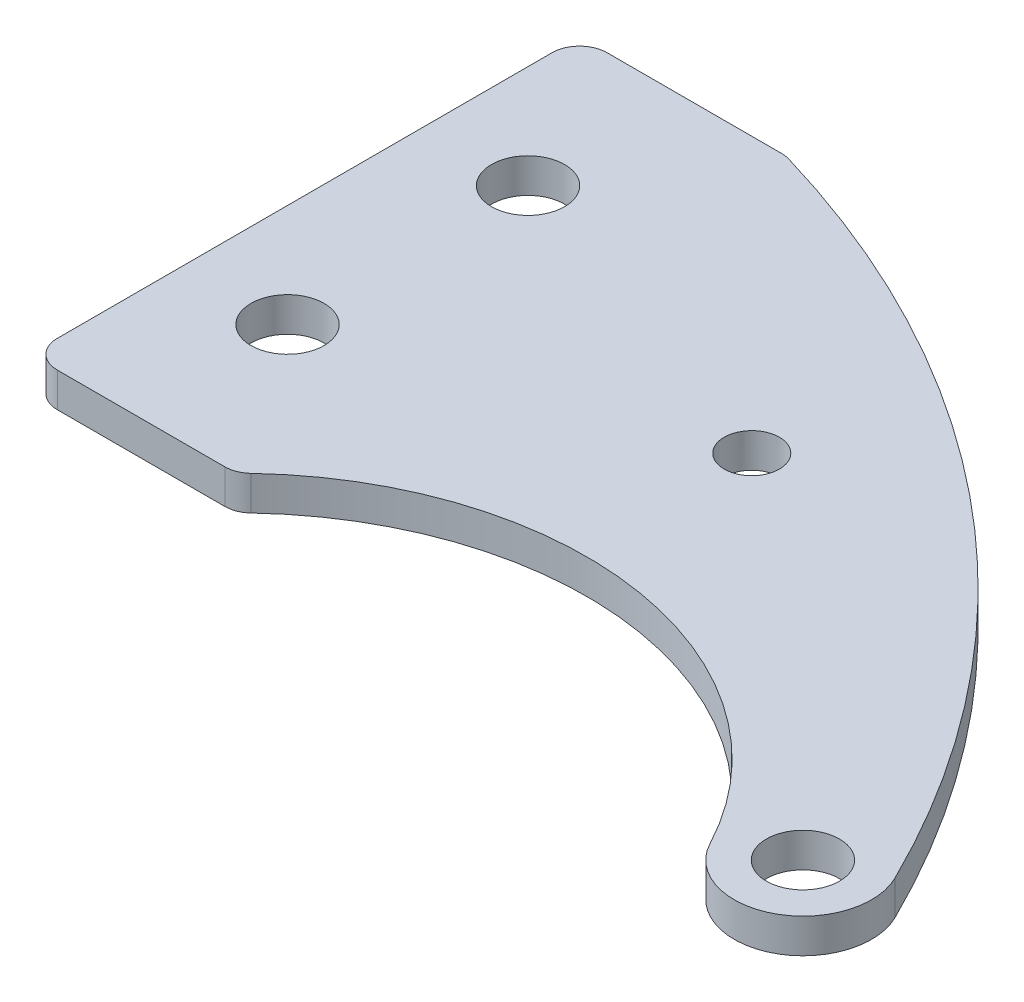
from build123d import *

# Parameters (mm, degrees)
BOSS_EXTRUDE1_DEPTH        = 3.175
F_1_4_CLEARANCE_HOLE2_D    = 6.7564
F_1_4_CLEARANCE_HOLE1_D    = 6.7564
FILLET1_R                  = 2.54
F_10_CLEARANCE_HOLE1_D     = 5.1054
F_10_CLEARANCE_HOLE1_DEPTH = 3.175


with BuildPart() as part:
    # Sketch1 → Boss-Extrude1 (new body)
    with BuildSketch(Plane(origin=(0, 0, 0), x_dir=(1, 0, 0), z_dir=(0, 1, 0))):
        with BuildLine():
            Line((0, 50.8), (19.05, 50.8))
            ThreePointArc((19.05, 50.8), (56.03836137, 31.046405743), (81.899154962, -1.962119182))
            ThreePointArc((81.899154962, -1.962119182), (79.082321477, -10.420655433), (70.584022136, -7.726162031))
            ThreePointArc((70.584022136, -7.726162031), (46.770595677, 9.16746016), (19.05, 0))
            Line((19.05, 0), (0, 0))
            Line((0, 0), (0, 50.8))
        make_face()
    extrude(amount=BOSS_EXTRUDE1_DEPTH)

    # 1/4 Clearance Hole2 (through all)
    with Locations(Plane(origin=(0, 0, 0), x_dir=(-1, 0, 0), z_dir=(0, -1, 0))):
        with Locations((-76.2, -4.7625)):
            Hole(F_1_4_CLEARANCE_HOLE2_D / 2)

    # 1/4 Clearance Hole1 (through all)
    with Locations(Plane(origin=(0, 3.175, 0), x_dir=(1, 0, 0), z_dir=(0, 1, 0))):
        with Locations((9.525, 36.5125), (9.525, 14.2875)):
            Hole(F_1_4_CLEARANCE_HOLE1_D / 2)

    # Fillet1
    fillet1_edges = [part.edges().sort_by_distance(p)[0] for p in [
        (0, 1.5875, -50.8),
        (19.05, 1.5875, -50.8),
        (19.05, 1.5875, 0),
        (0, 1.5875, 0),
    ]]
    fillet(fillet1_edges, radius=FILLET1_R)

    # #10 Clearance Hole1
    with Locations(Plane(origin=(0, 3.175, 0), x_dir=(1, 0, 0), z_dir=(0, 1, 0))):
        with Locations((41.275, 25.437101907)):
            Hole(F_10_CLEARANCE_HOLE1_D / 2, depth=F_10_CLEARANCE_HOLE1_DEPTH)


solid = part.part
